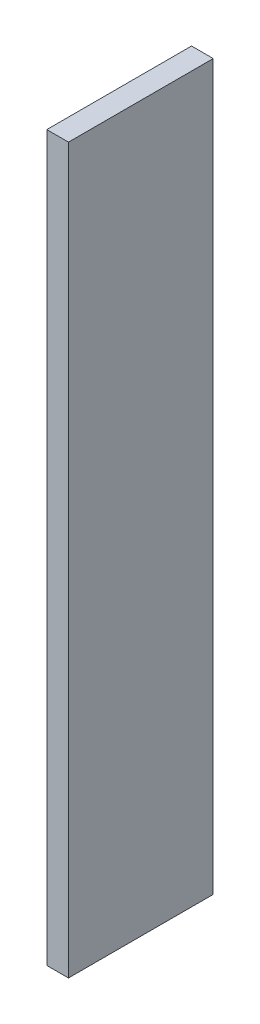
from build123d import *

# Parameters (mm, degrees)
SKETCH1_W           = 20
SKETCH1_H           = 100
BOSS_EXTRUDE1_DEPTH = 3


with BuildPart() as part:
    # Sketch1 → Boss-Extrude1 (new body)
    with BuildSketch(Plane(origin=(0, 0, 0), x_dir=(0, 0, -1), z_dir=(1, 0, 0))):
        Rectangle(SKETCH1_W, SKETCH1_H)
    extrude(amount=BOSS_EXTRUDE1_DEPTH)


solid = part.part
